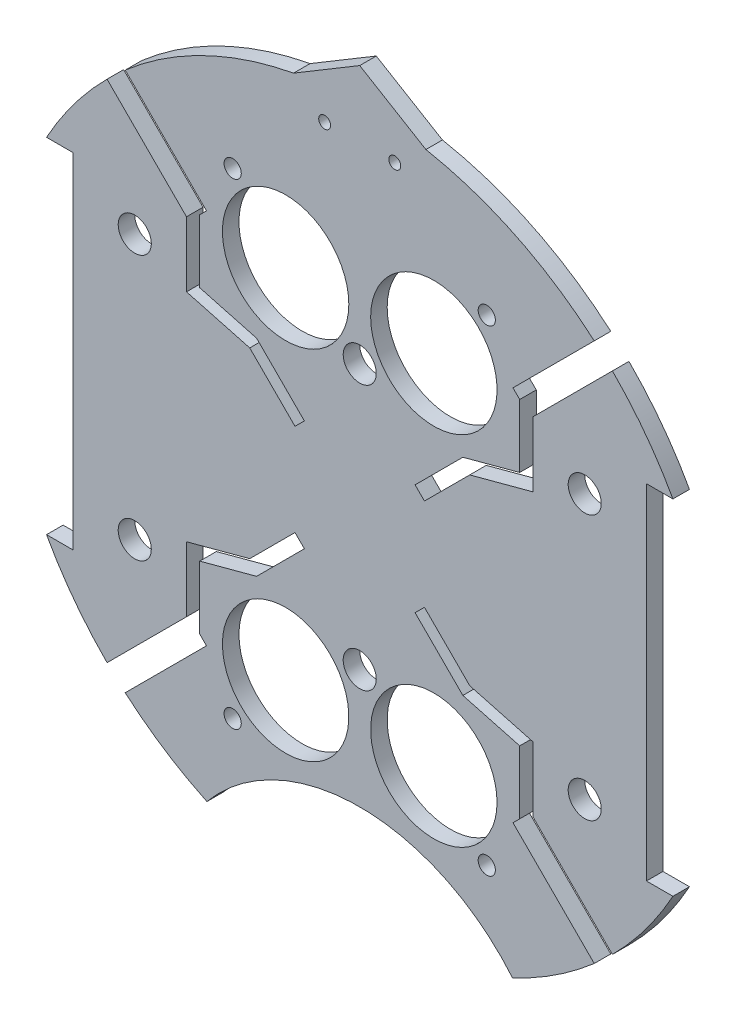
from build123d import *

# Parameters (mm, degrees)
BOSS_EXTRUDE2_DEPTH = 3.175
SKETCH3_R           = 12.1285
CUT_EXTRUDE2_DEPTH  = 92.247975457
SKETCH4_R           = 38.1
CUT_EXTRUDE3_DEPTH  = 92.247975457
CUT_EXTRUDE6_DEPTH  = 92.247975457
BOSS_EXTRUDE3_DEPTH = 3.175
SKETCH12_R          = 1.143
CUT_EXTRUDE9_DEPTH  = 97.166400707
SKETCH13_R          = 1.651
CUT_EXTRUDE10_DEPTH = 55.88
SKETCH14_R          = 3.175
CUT_EXTRUDE11_DEPTH = 129.184225337


with BuildPart() as part:
    # Sketch1 → Boss-Extrude2 (new body)
    with BuildSketch(Plane.XY):
        with BuildLine():
            Line((-60.107370596, 33.02), (-55.027370596, 33.02))
            Line((-55.027370596, 33.02), (-55.027370596, -33.02))
            Line((-55.027370596, -33.02), (-60.107370596, -33.02))
            ThreePointArc((-60.107370596, -33.02), (0, -68.58), (60.107370596, -33.02))
            Line((60.107370596, -33.02), (55.027370596, -33.02))
            Line((55.027370596, -33.02), (55.027370596, 33.02))
            Line((55.027370596, 33.02), (60.107370596, 33.02))
            ThreePointArc((60.107370596, 33.02), (0, 68.58), (-60.107370596, 33.02))
        make_face()
    extrude(amount=BOSS_EXTRUDE2_DEPTH)

    # Sketch3 → Cut-Extrude2 (cut, through all)
    with BuildSketch(Plane(origin=(0, 0, 0), x_dir=(-1, 0, 0), z_dir=(0, 0, -1))):
        with Locations((14.224, -34.29)):
            Circle(SKETCH3_R)
        with Locations(Location((14.224, 34.29, 0), (0, 0, 180))):
            Circle(SKETCH3_R)
        with Locations((-14.224, 34.29)):
            Circle(SKETCH3_R)
        with Locations(Location((-14.224, -34.29, 0), (0, 0, 180))):
            Circle(SKETCH3_R)
    extrude(amount=-CUT_EXTRUDE2_DEPTH, mode=Mode.SUBTRACT)

    # Sketch4 → Cut-Extrude3 (cut, through all)
    with BuildSketch(Plane(origin=(0, 0, 0), x_dir=(-1, 0, 0), z_dir=(0, 0, -1))):
        with Locations((0, -86.312058398)):
            Circle(SKETCH4_R)
    extrude(amount=-CUT_EXTRUDE3_DEPTH, mode=Mode.SUBTRACT)

    # Sketch5 → Cut-Extrude6 (cut, through all)
    with BuildSketch(Plane(origin=(0, 0, 0), x_dir=(-1, 0, 0), z_dir=(0, 0, -1))):
        with BuildLine():
            Line((10.776307345, -10.776307345), (19.793695097, -19.793695097))
            Line((19.793695097, -19.793695097), (30.704765274, -22.71730754))
            Line((30.704765274, -22.71730754), (30.704765274, -34.85110441))
            Line((30.704765274, -34.85110441), (29.410338797, -36.145530887))
            Line((29.410338797, -36.145530887), (45.008715274, -51.743907365))
            ThreePointArc((45.008715274, -51.743907365), (46.779291091, -50.148921474), (48.493383054, -48.493383054))
            Line((48.493383054, -48.493383054), (33.244765274, -33.244765274))
            Line((33.244765274, -33.244765274), (33.244765274, -20.76829699))
            Line((33.244765274, -20.76829699), (21.108495846, -17.516393398))
            Line((21.108495846, -17.516393398), (12.421633561, -8.829531113))
            Line((12.421633561, -8.829531113), (10.625582337, -10.625582337))
            Line((10.625582337, -10.625582337), (10.776307345, -10.776307345))
        make_face()
        with BuildLine():
            Line((-10.776307345, -10.776307345), (-10.625582337, -10.625582337))
            Line((-10.625582337, -10.625582337), (-12.421633561, -8.829531113))
            Line((-12.421633561, -8.829531113), (-21.108495846, -17.516393398))
            Line((-21.108495846, -17.516393398), (-33.244765274, -20.76829699))
            Line((-33.244765274, -20.76829699), (-33.244765274, -33.244765274))
            Line((-33.244765274, -33.244765274), (-48.493383054, -48.493383054))
            ThreePointArc((-48.493383054, -48.493383054), (-46.779291091, -50.148921474), (-45.008715274, -51.743907365))
            Line((-45.008715274, -51.743907365), (-29.410338797, -36.145530887))
            Line((-29.410338797, -36.145530887), (-30.704765274, -34.85110441))
            Line((-30.704765274, -34.85110441), (-30.704765274, -22.71730754))
            Line((-30.704765274, -22.71730754), (-19.793695097, -19.793695097))
            Line((-19.793695097, -19.793695097), (-10.776307345, -10.776307345))
        make_face()
        with BuildLine():
            Line((-10.776307345, 10.776307345), (-19.793695097, 19.793695097))
            Line((-19.793695097, 19.793695097), (-30.704765274, 22.71730754))
            Line((-30.704765274, 22.71730754), (-30.704765274, 34.85110441))
            Line((-30.704765274, 34.85110441), (-29.410338797, 36.145530887))
            Line((-29.410338797, 36.145530887), (-45.008715274, 51.743907365))
            ThreePointArc((-45.008715274, 51.743907365), (-46.779291091, 50.148921474), (-48.493383054, 48.493383054))
            Line((-48.493383054, 48.493383054), (-33.244765274, 33.244765274))
            Line((-33.244765274, 33.244765274), (-33.244765274, 20.76829699))
            Line((-33.244765274, 20.76829699), (-21.108495846, 17.516393398))
            Line((-21.108495846, 17.516393398), (-12.421633561, 8.829531113))
            Line((-12.421633561, 8.829531113), (-10.625582337, 10.625582337))
            Line((-10.625582337, 10.625582337), (-10.776307345, 10.776307345))
        make_face()
        with BuildLine():
            ThreePointArc((48.493383054, 48.493383054), (46.779291091, 50.148921474), (45.008715274, 51.743907365))
            Line((45.008715274, 51.743907365), (29.410338797, 36.145530887))
            Line((29.410338797, 36.145530887), (30.704765274, 34.85110441))
            Line((30.704765274, 34.85110441), (30.704765274, 22.71730754))
            Line((30.704765274, 22.71730754), (19.793695097, 19.793695097))
            Line((19.793695097, 19.793695097), (10.776307345, 10.776307345))
            Line((10.776307345, 10.776307345), (10.625582337, 10.625582337))
            Line((10.625582337, 10.625582337), (12.421633561, 8.829531113))
            Line((12.421633561, 8.829531113), (21.108495846, 17.516393398))
            Line((21.108495846, 17.516393398), (33.244765274, 20.76829699))
            Line((33.244765274, 20.76829699), (33.244765274, 33.244765274))
            Line((33.244765274, 33.244765274), (48.493383054, 48.493383054))
        make_face()
    extrude(amount=-CUT_EXTRUDE6_DEPTH, mode=Mode.SUBTRACT)

    # Sketch9 → Boss-Extrude3 (add)
    with BuildSketch(Plane(origin=(0, 0, 0), x_dir=(-1, 0, 0), z_dir=(0, 0, -1))):
        with BuildLine():
            Line((12.7, 67.39381574), (0, 75))
            Line((0, 75), (-12.7, 67.39381574))
            ThreePointArc((-12.7, 67.39381574), (0, 68.58), (12.7, 67.39381574))
        make_face()
    extrude(amount=-BOSS_EXTRUDE3_DEPTH)

    # Sketch12 → Cut-Extrude9 (cut, through all)
    with BuildSketch(Plane(origin=(0, 0, 0), x_dir=(-1, 0, 0), z_dir=(0, 0, -1))):
        with Locations((6.731, 62.23)):
            Circle(SKETCH12_R)
        with Locations((-6.731, 62.23)):
            Circle(SKETCH12_R)
    extrude(amount=-CUT_EXTRUDE9_DEPTH, mode=Mode.SUBTRACT)

    # Sketch13 → Cut-Extrude10 (cut)
    with BuildSketch(Plane(origin=(30.092005081, 4.08352975, 15.875), x_dir=(1, 0, 0), z_dir=(0, 0, 1))):
        with Locations((-54.476005081, -49.80352975)):
            Circle(SKETCH13_R)
        with Locations((-54.476005081, 41.63647025)):
            Circle(SKETCH13_R)
        with Locations((-5.708005081, -49.80352975)):
            Circle(SKETCH13_R)
        with Locations((-5.708005081, 41.63647025)):
            Circle(SKETCH13_R)
    extrude(amount=-CUT_EXTRUDE10_DEPTH, mode=Mode.SUBTRACT)

    # Sketch14 → Cut-Extrude11 (cut, through all)
    with BuildSketch(Plane(origin=(30.092005081, 4.08352975, -53.975), x_dir=(-1, 0, 0), z_dir=(0, 0, -1))):
        with Locations(Location((-13.087994919, 21.31647025, 0), (0, 0, 180))):
            Circle(SKETCH14_R)
        with Locations((73.272005081, 21.31647025)):
            Circle(SKETCH14_R)
        with Locations((30.092005081, 21.31647025)):
            Circle(SKETCH14_R)
        with Locations(Location((73.272005081, -29.48352975, 0), (0, 0, 180))):
            Circle(SKETCH14_R)
        with Locations(Location((30.092005081, -29.48352975, 0), (0, 0, 180))):
            Circle(SKETCH14_R)
        with Locations((-13.087994919, -29.48352975)):
            Circle(SKETCH14_R)
    extrude(amount=-CUT_EXTRUDE11_DEPTH, mode=Mode.SUBTRACT)


solid = part.part
